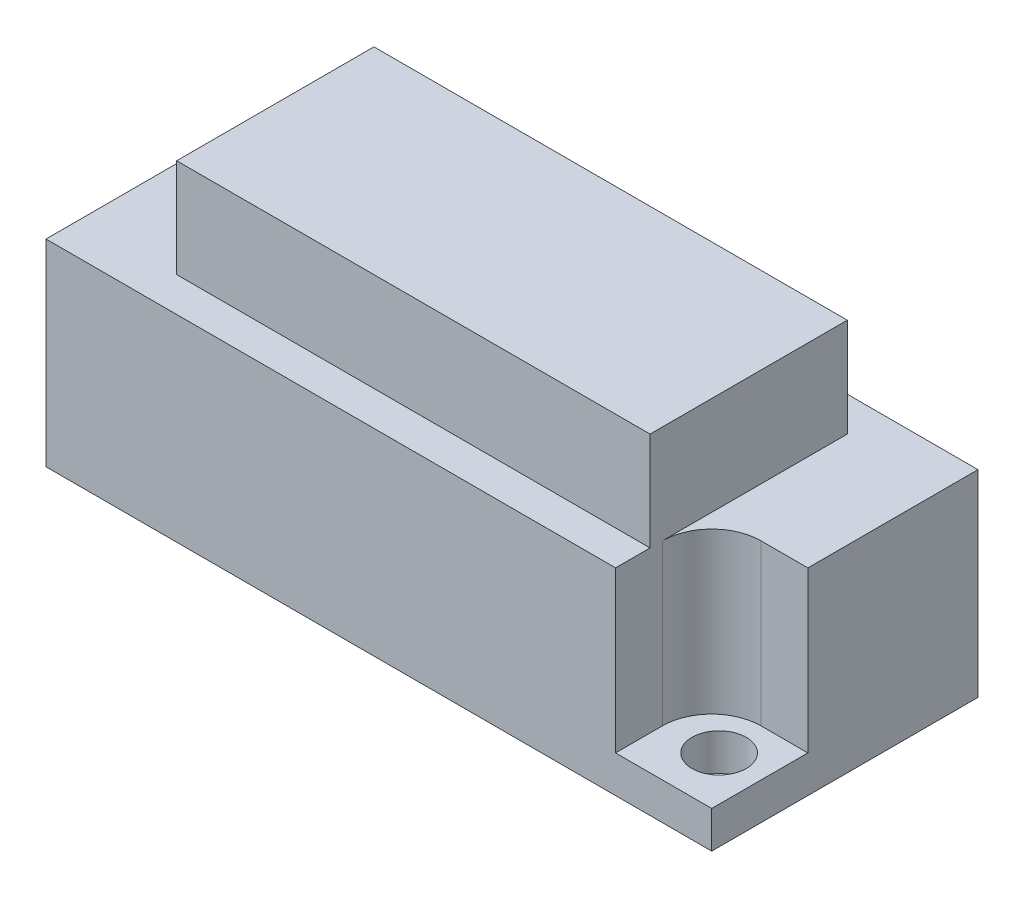
from build123d import *

# Parameters (mm, degrees)
SKETCH_1_W          = 27
SKETCH_1_H          = 10.8
EXTRUDE_1_DEPTH     = 12
SKETCH_2_W          = 3.9
SKETCH_2_H          = 3.9
CUT_EXTRUDE_1_DEPTH = 10.5
FILLET_1_R          = 2
SKETCH_3_R          = 1.1
CUT_EXTRUDE_2_DEPTH = 40.5
SKETCH_4_W          = 27
SKETCH_4_H          = 10.8
SKETCH_4_W_2        = 19.2
SKETCH_4_H_2        = 8
CUT_EXTRUDE_3_DEPTH = 4


with BuildPart() as part:
    # 스케치1 → 보스-돌출1 (new body)
    with BuildSketch(Plane(origin=(0, 0, 0), x_dir=(1, 0, 0), z_dir=(0, 1, 0))):
        Rectangle(SKETCH_1_W, SKETCH_1_H)
    extrude(amount=EXTRUDE_1_DEPTH)

    # 스케치2 → 컷-돌출1 (cut)
    with BuildSketch(Plane(origin=(0, 12, 0), x_dir=(1, 0, 0), z_dir=(0, 1, 0))):
        with Locations((-11.55, 3.45)):
            Rectangle(SKETCH_2_W, SKETCH_2_H)
        with Locations((11.55, -3.45)):
            Rectangle(SKETCH_2_W, SKETCH_2_H)
    extrude(amount=-CUT_EXTRUDE_1_DEPTH, mode=Mode.SUBTRACT)

    # 필렛1
    fillet_1_edges = [part.edges().sort_by_distance(p)[0] for p in [
        (-9.6, 6.75, -1.5),
        (9.6, 6.75, 1.5),
    ]]
    fillet(fillet_1_edges, radius=FILLET_1_R)

    # 스케치3 → 컷-돌출2 (cut)
    with BuildSketch(Plane(origin=(0, 12, 0), x_dir=(1, 0, 0), z_dir=(0, 1, 0))):
        with Locations((-11.7, 3.3)):
            Circle(SKETCH_3_R)
        with Locations((11.7, -3.3)):
            Circle(SKETCH_3_R)
    extrude(amount=-CUT_EXTRUDE_2_DEPTH, mode=Mode.SUBTRACT)

    # 스케치4 → 컷-돌출3 (cut)
    with BuildSketch(Plane(origin=(0, 12, 0), x_dir=(1, 0, 0), z_dir=(0, 1, 0))):
        Rectangle(SKETCH_4_W, SKETCH_4_H)
        Rectangle(SKETCH_4_W_2, SKETCH_4_H_2, mode=Mode.SUBTRACT)
    extrude(amount=-CUT_EXTRUDE_3_DEPTH, mode=Mode.SUBTRACT)


solid = part.part
